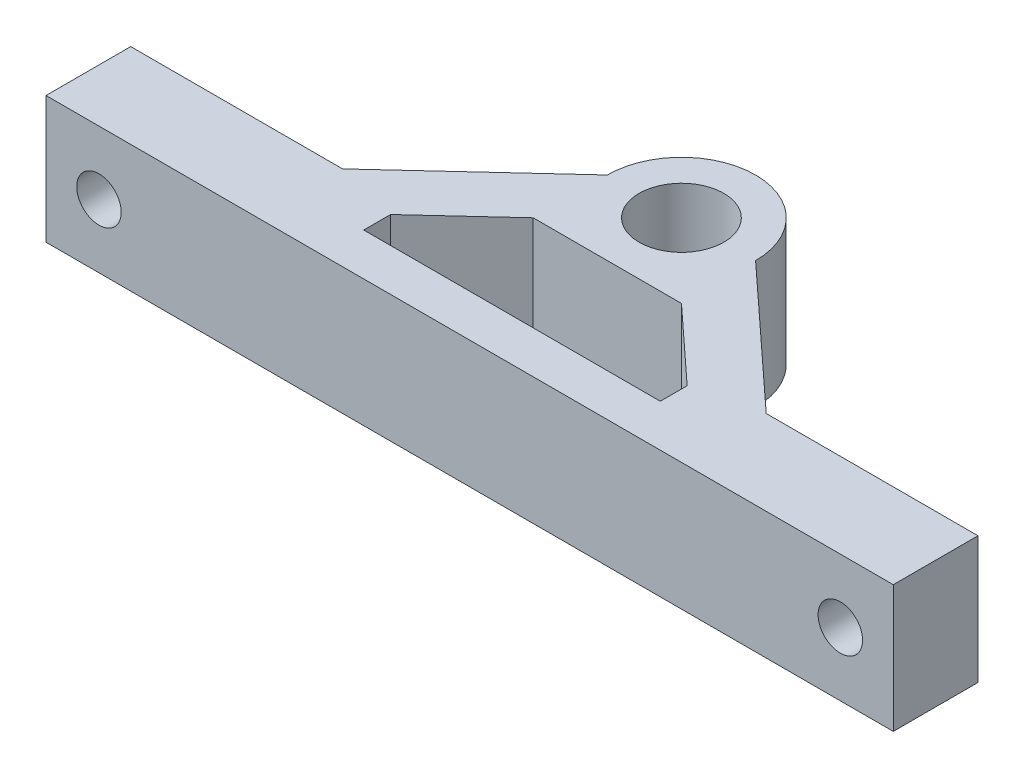
from build123d import *

# Parameters (mm, degrees)
SKETCH_1_R            = 4
EXTRUDE_1_DEPTH       = 12
HOLE_WIZARD_M41_D     = 4.2
HOLE_WIZARD_M41_DEPTH = 8
HOLE_WIZARD_M41_TIP   = 1.2618073


with BuildPart() as part:
    # Эскиз1 → Бобышка-Вытянуть1 (new body)
    with BuildSketch(Plane(origin=(0, 0, 0), x_dir=(1, 0, 0), z_dir=(0, 1, 0))):
        with BuildLine():
            Line((-40, -20), (40, -20))
            Line((40, -20), (40, -12))
            Line((40, -12), (20, -12))
            Line((20, -12), (7, 0))
            ThreePointArc((7, 0), (0, 7), (-7, 0))
            Line((-7, 0), (-20, -12))
            Line((-20, -12), (-40, -12))
            Line((-40, -12), (-40, -20))
        make_face()
        Circle(SKETCH_1_R, mode=Mode.SUBTRACT)
        Polygon((-14, -16), (14, -16), (14, -13.461538462), (7, -7), (-7, -7), (-14, -13.461538462), align=None, mode=Mode.SUBTRACT)
    extrude(amount=EXTRUDE_1_DEPTH)

    # Сверло под метчик  спиральное M41
    with Locations(Plane.XY.offset(20)):
        with Locations((-35, 6), (35, 6)):
            Hole(HOLE_WIZARD_M41_D / 2, depth=HOLE_WIZARD_M41_DEPTH)
            with Locations((0, 0, -(HOLE_WIZARD_M41_DEPTH + HOLE_WIZARD_M41_TIP / 2))):  # 118° drill point
                Cone(0, HOLE_WIZARD_M41_D / 2, HOLE_WIZARD_M41_TIP, mode=Mode.SUBTRACT)


solid = part.part
